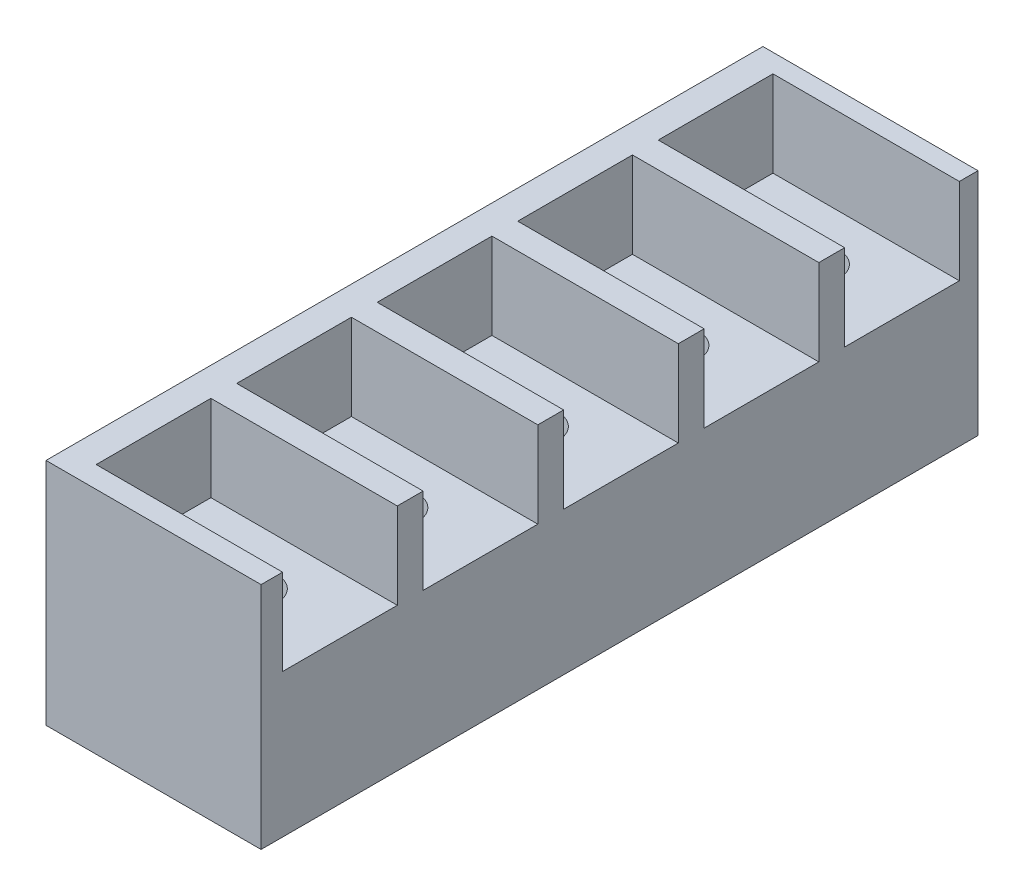
from build123d import *

# Parameters (mm, degrees)
SKETCH1_W             = 15
SKETCH1_H             = 50
BOSS_EXTRUDE1_DEPTH   = 16
SKETCH2_W             = 13
SKETCH2_H             = 8
CUT_EXTRUDE1_DEPTH    = 6
M4_TAPPED_HOLE2_D     = 3.3
M4_TAPPED_HOLE2_DEPTH = 6
M4_TAPPED_HOLE2_TIP   = 0.991420021


with BuildPart() as part:
    # Sketch1 → Boss-Extrude1 (new body)
    with BuildSketch(Plane(origin=(0, 0, 0), x_dir=(1, 0, 0), z_dir=(0, 1, 0))):
        with Locations((7.5, 25)):
            Rectangle(SKETCH1_W, SKETCH1_H)
    extrude(amount=BOSS_EXTRUDE1_DEPTH)

    # Sketch2 → Cut-Extrude1 (cut)
    with BuildSketch(Plane(origin=(0, 16, 0), x_dir=(1, 0, 0), z_dir=(0, 1, 0))):
        with Locations((8.5, 5.5)):
            Rectangle(SKETCH2_W, SKETCH2_H)
        with Locations((8.5, 15.3)):
            Rectangle(SKETCH2_W, SKETCH2_H)
        with Locations((8.5, 25.1)):
            Rectangle(SKETCH2_W, SKETCH2_H)
        with Locations((8.5, 34.9)):
            Rectangle(SKETCH2_W, SKETCH2_H)
        with Locations((8.5, 44.7)):
            Rectangle(SKETCH2_W, SKETCH2_H)
    extrude(amount=-CUT_EXTRUDE1_DEPTH, mode=Mode.SUBTRACT)

    # M4 Tapped Hole2
    with Locations(Plane(origin=(0, 10, 0), x_dir=(1, 0, 0), z_dir=(0, 1, 0))):
        with Locations((9, 5.5), (9, 15.3), (9, 25.1), (9, 34.9), (9, 44.7)):
            Hole(M4_TAPPED_HOLE2_D / 2, depth=M4_TAPPED_HOLE2_DEPTH)
            with Locations((0, 0, -(M4_TAPPED_HOLE2_DEPTH + M4_TAPPED_HOLE2_TIP / 2))):  # 118° drill point
                Cone(0, M4_TAPPED_HOLE2_D / 2, M4_TAPPED_HOLE2_TIP, mode=Mode.SUBTRACT)


solid = part.part
